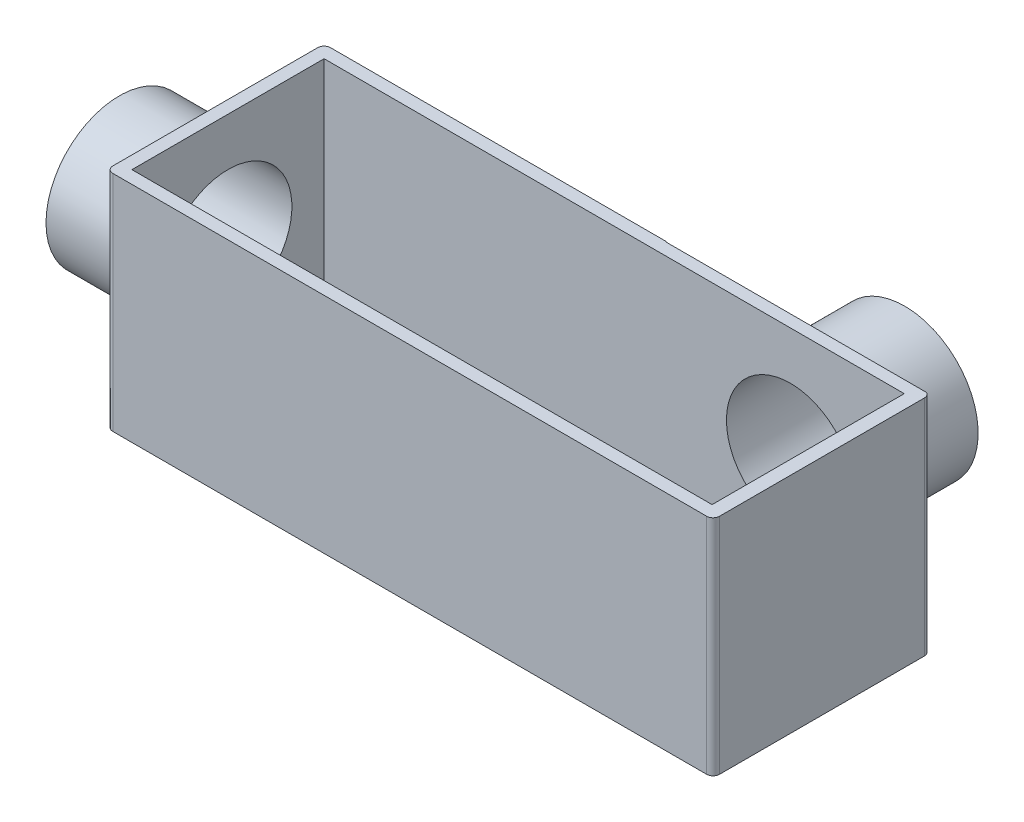
from build123d import *

# Parameters (mm, degrees)
SALIENTE_EXTRUIR1_DEPTH = 35
CROQUIS2_R              = 23.966278947
CROQUIS2_R_2            = 11.5
CORTAR_EXTRUIR1_DEPTH   = 15
CROQUIS3_R              = 27.659664681
CROQUIS3_R_2            = 11.5
CORTAR_EXTRUIR2_DEPTH   = 16
CROQUIS4_W              = 90.840335319
CROQUIS4_H              = 30.090909091
CORTAR_EXTRUIR3_DEPTH   = 33
CROQUIS5_R              = 10
CORTAR_EXTRUIR5_DEPTH   = 33
CROQUIS6_R              = 10
CORTAR_EXTRUIR6_DEPTH   = 33


with BuildPart() as part:
    # Croquis1 → Saliente-Extruir1 (new body)
    with BuildSketch(Plane(origin=(0, 0, 0), x_dir=(1, 0, 0), z_dir=(0, 1, 0))):
        with BuildLine():
            Line((54, -25), (-39, -25))
            ThreePointArc((-39, -25), (-39.707106781, -24.707106781), (-40, -24))
            Line((-40, -24), (-40, -23.954545455))
            ThreePointArc((-40, -23.954545455), (-40.292893219, -23.247438673), (-41, -22.954545455))
            Line((-41, -22.954545455), (-54, -22.954545455))
            ThreePointArc((-54, -22.954545455), (-54.707106781, -22.661652236), (-55, -21.954545455))
            Line((-55, -21.954545455), (-55, 6.045454545))
            ThreePointArc((-55, 6.045454545), (-54.707106781, 6.752561327), (-54, 7.045454545))
            Line((-54, 7.045454545), (-41, 7.045454545))
            ThreePointArc((-41, 7.045454545), (-40.292893219, 7.338347764), (-40, 8.045454545))
            Line((-40, 8.045454545), (-40, 8.090909091))
            ThreePointArc((-40, 8.090909091), (-39.707106781, 8.798015872), (-39, 9.090909091))
            Line((-39, 9.090909091), (19, 9.090909091))
            ThreePointArc((19, 9.090909091), (19.707106781, 9.38380231), (20, 10.090909091))
            Line((20, 10.090909091), (20, 24))
            ThreePointArc((20, 24), (20.292893219, 24.707106781), (21, 25))
            Line((21, 25), (49, 25))
            ThreePointArc((49, 25), (49.707106781, 24.707106781), (50, 24))
            Line((50, 24), (50, 10.090909091))
            ThreePointArc((50, 10.090909091), (50.292893219, 9.38380231), (51, 9.090909091))
            Line((51, 9.090909091), (54, 9.090909091))
            ThreePointArc((54, 9.090909091), (54.707106781, 8.798015872), (55, 8.090909091))
            Line((55, 8.090909091), (55, -24))
            ThreePointArc((55, -24), (54.707106781, -24.707106781), (54, -25))
        make_face()
    extrude(amount=SALIENTE_EXTRUIR1_DEPTH)

    # Croquis2 → Cortar-Extruir1 (cut)
    with BuildSketch(Plane.ZY.offset(55)):
        with Locations((7.954545455, 17.5)):
            Circle(CROQUIS2_R)
        with Locations((7.954545455, 17.5)):
            Circle(CROQUIS2_R_2, mode=Mode.SUBTRACT)
    extrude(amount=-CORTAR_EXTRUIR1_DEPTH, mode=Mode.SUBTRACT)

    # Croquis3 → Cortar-Extruir2 (cut)
    with BuildSketch(Plane(origin=(0, 0, -25), x_dir=(-1, 0, 0), z_dir=(0, 0, -1))):
        with Locations((-35, 17.5)):
            Circle(CROQUIS3_R)
        with Locations((-35, 17.5)):
            Circle(CROQUIS3_R_2, mode=Mode.SUBTRACT)
    extrude(amount=-CORTAR_EXTRUIR2_DEPTH, mode=Mode.SUBTRACT)

    # Croquis4 → Cortar-Extruir3 (cut)
    with BuildSketch(Plane(origin=(0, 35, 0), x_dir=(1, 0, 0), z_dir=(0, 1, 0))):
        with Locations((7.42016766, -7.954545454)):
            Rectangle(CROQUIS4_W, CROQUIS4_H)
    extrude(amount=-CORTAR_EXTRUIR3_DEPTH, mode=Mode.SUBTRACT)

    # Croquis5 → Cortar-Extruir5 (cut)
    with BuildSketch(Plane.ZY.offset(55)):
        with Locations((7.954545455, 17.5)):
            Circle(CROQUIS5_R)
    extrude(amount=-CORTAR_EXTRUIR5_DEPTH, mode=Mode.SUBTRACT)

    # Croquis6 → Cortar-Extruir6 (cut)
    with BuildSketch(Plane(origin=(0, 0, -25), x_dir=(-1, 0, 0), z_dir=(0, 0, -1))):
        with Locations((-35, 17.5)):
            Circle(CROQUIS6_R)
    extrude(amount=-CORTAR_EXTRUIR6_DEPTH, mode=Mode.SUBTRACT)


solid = part.part
